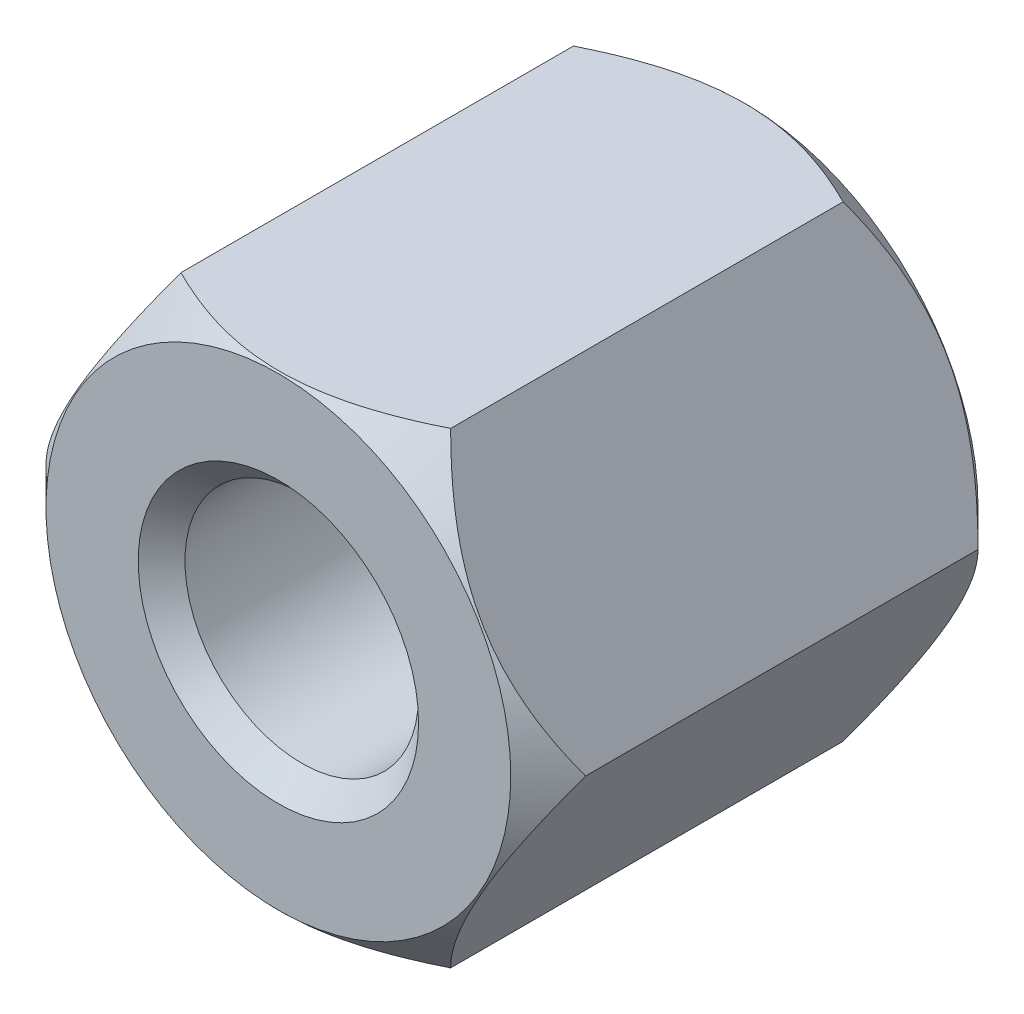
from build123d import *

# Parameters (mm, degrees)
HEX_2_DEPTH                 = 2.5
TAP_DRILL_FOR_M3X0_5_TAP1_D = 2.5
INNERCHAMFER_SIZE           = 0.25


with BuildPart() as part:
    # Sketch1 → HEX 2 (new body, symmetric)
    with BuildSketch(Plane.XY):
        Polygon((2.886751346, 0), (1.443375673, 2.5), (-1.443375673, 2.5), (-2.886751346, 0), (-1.443375673, -2.5), (1.443375673, -2.5), align=None)
    extrude(amount=HEX_2_DEPTH, both=True)

    # Tap Drill for M3x0.5 Tap1 (through all)
    with Locations(Plane.XY.offset(2.5)):
        with Locations((0, 0)):
            Hole(TAP_DRILL_FOR_M3X0_5_TAP1_D / 2)

    # Sketch7 → HexChamfer (revolve, cut)
    with BuildSketch(Plane(origin=(0, 0, 0), x_dir=(1, 0, 0), z_dir=(0, 1, 0))):
        Polygon((-2.886751346, 2.5), (-2.886751346, 2.1), (-2.486751346, 2.5), align=None)
    hexchamfer = revolve(axis=Axis((0, 0, 15.266742202), (0, 0, -1)), mode=Mode.SUBTRACT)

    # Mirror1: HexChamfer across plane
    add(hexchamfer.mirror(Plane.XY), mode=Mode.SUBTRACT)

    # InnerChamfer
    innerchamfer_edges = [part.edges().sort_by_distance(p)[0] for p in [
        (1.25, 0, 2.5),
        (1.25, 0, -2.5),
    ]]
    chamfer(innerchamfer_edges, length=INNERCHAMFER_SIZE)


solid = part.part
